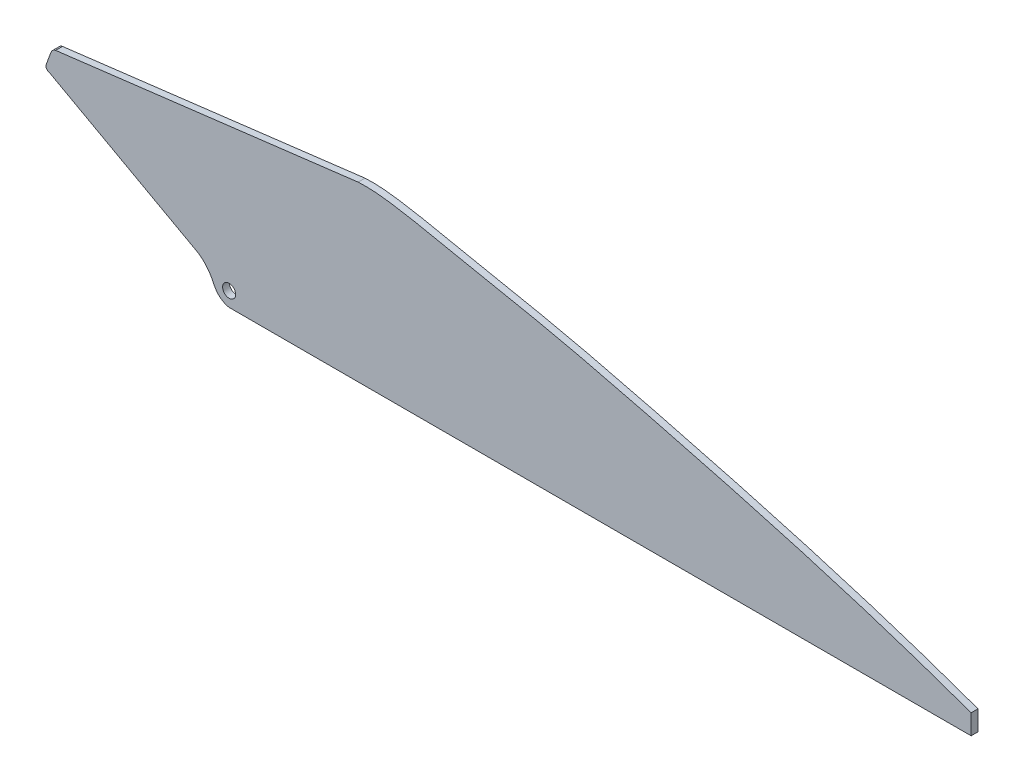
from build123d import *

# Parameters (mm, degrees)
SKETCH1_R           = 6.223
BOSS_EXTRUDE1_DEPTH = 6.5532


with BuildPart() as part:
    # Sketch1 → Boss-Extrude1 (new body)
    with BuildSketch(Plane.XY):
        with BuildLine():
            Line((7.863413581, -33.869503221), (715.888413581, -33.869503221))
            Line((715.888413581, -33.869503221), (715.888413581, -14.819503221))
            add(Edge.make_bspline(
                [(130.923235962, 131.230496779), (144.565200568, 132.032600728), (175.745486699, 127.859730288), (235.979768818, 114.85150342), (312.791548306, 100.519974188), (477.93566039, 59.855493816), (612.69545282, 22.729861701), (715.888413581, -14.819503221)],
                knots=[0, 0, 0, 0, 0.067559052, 0.155584559, 0.306170235, 0.45538855, 1, 1, 1, 1], degree=3))
            Line((130.923235962, 131.230496779), (-157.661182161, 95.771476732))
            add(Edge.make_bspline(
                [(-162.045338663, 92.076043846), (-160.791359706, 95.015911404), (-157.661182161, 95.771476732)],
                knots=[0, 0, 0, 1, 1, 1], degree=2))
            Line((-162.045338663, 92.076043846), (-166.007371822, 81.448210611))
            add(Edge.make_bspline(
                [(-166.007371822, 81.448210611), (-168.608963638, 75.860668743), (-163.225353362, 74.245207536)],
                knots=[0, 0, 0, 1, 1, 1], degree=2))
            Line((-163.225353362, 74.245207536), (-21.760854311, -3.492806329))
            add(Edge.make_bspline(
                [(-21.760854311, -3.492806329), (-15.52403959, -7.589674855), (-9.833439316, -14.720767687), (-4.017541939, -28.023280736), (2.081063731, -32.902187391), (7.863413581, -33.869503221)],
                knots=[0, 0, 0, 0, 0.506293101, 0.611828229, 1, 1, 1, 1], degree=3))
        make_face()
        with Locations((7.863413581, -20.081840024)):
            Circle(SKETCH1_R, mode=Mode.SUBTRACT)
    extrude(amount=BOSS_EXTRUDE1_DEPTH)


solid = part.part
